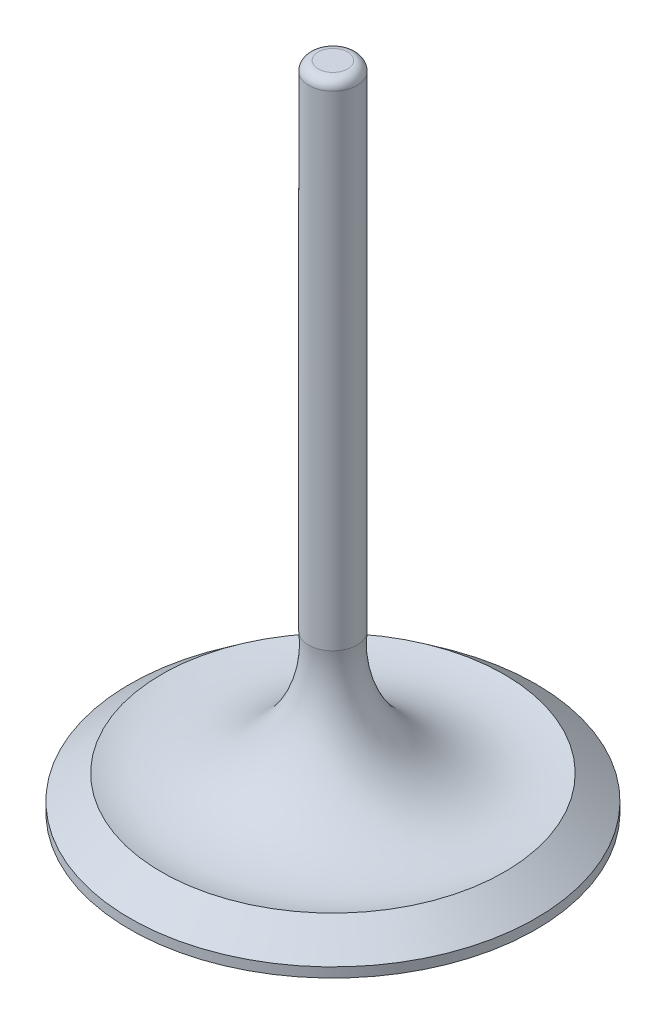
from build123d import *

# Parameters (mm, degrees)
FILLET1_R = 1.25


with BuildPart() as part:
    # Sketch1 → Revolve1 (revolve)
    with BuildSketch(Plane(origin=(0, 0, 0), x_dir=(0, 0, -1), z_dir=(1, 0, 0))):
        with BuildLine():
            Line((0, 0), (0, 85.55))
            Line((0, 85.55), (3.18, 85.55))
            Line((3.18, 85.55), (3.18, 20.623345081))
            ThreePointArc((3.18, 20.623345081), (8.570011584, 7.427407082), (22.50988431, 4.45))
            Line((22.50988431, 4.45), (26.67, 1.27))
            Line((26.67, 1.27), (26.67, 0))
            Line((26.67, 0), (0, 0))
        make_face()
    revolve(axis=Axis((0, 0, 0), (0, 1, 0)))

    # Fillet1
    fillet1_edges = [part.edges().sort_by_distance(p)[0] for p in [
        (0, 85.55, 3.18),
    ]]
    fillet(fillet1_edges, radius=FILLET1_R)


solid = part.part
